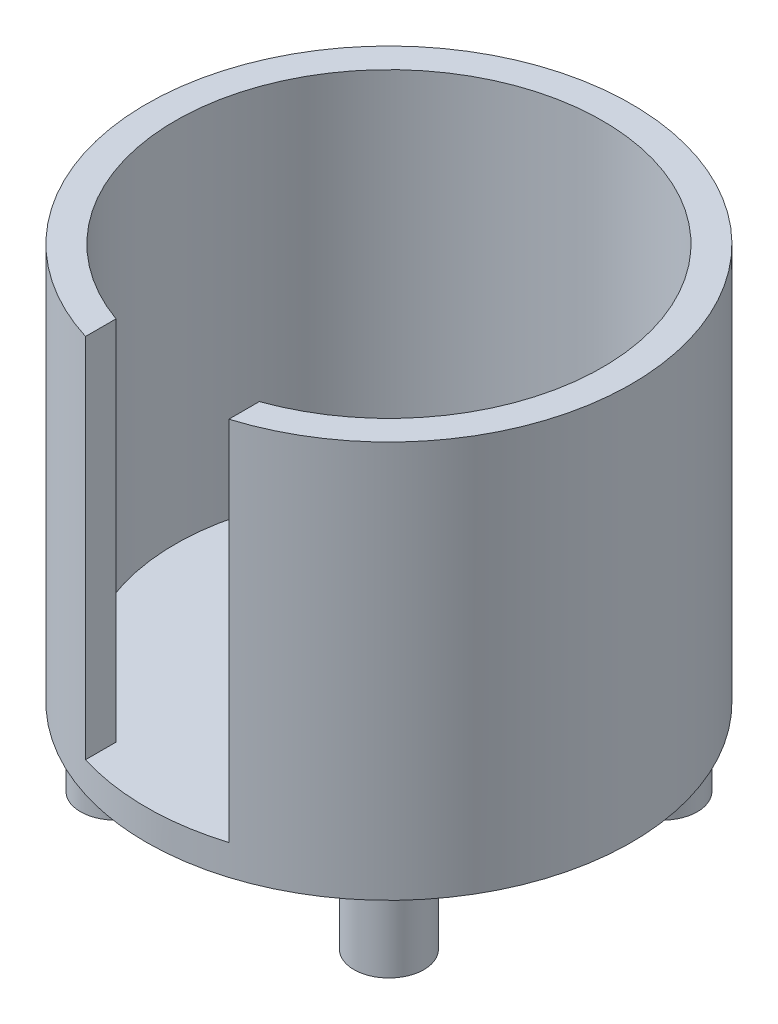
from build123d import *

# Parameters (mm, degrees)
SKETCH1_R           = 22
BOSS_EXTRUDE1_DEPTH = 36
SKETCH3_R           = 19.375
CUT_EXTRUDE1_DEPTH  = 33.25
SKETCH4_W           = 13
SKETCH4_H           = 8.241634072
CUT_EXTRUDE2_DEPTH  = 33.25
SKETCH5_R           = 3.175
BOSS_EXTRUDE2_DEPTH = 7


with BuildPart() as part:
    # Sketch1 → Boss-Extrude1 (new body)
    with BuildSketch(Plane(origin=(0, 0, 0), x_dir=(1, 0, 0), z_dir=(0, 1, 0))):
        Circle(SKETCH1_R)
    extrude(amount=BOSS_EXTRUDE1_DEPTH)

    # Sketch3 → Cut-Extrude1 (cut)
    with BuildSketch(Plane(origin=(0, 36, 0), x_dir=(1, 0, 0), z_dir=(0, 1, 0))):
        Circle(SKETCH3_R)
    extrude(amount=-CUT_EXTRUDE1_DEPTH, mode=Mode.SUBTRACT)

    # Sketch4 → Cut-Extrude2 (cut)
    with BuildSketch(Plane(origin=(0, 36, 0), x_dir=(1, 0, 0), z_dir=(0, 1, 0))):
        with Locations((0, -20.83301946)):
            Rectangle(SKETCH4_W, SKETCH4_H)
    extrude(amount=-CUT_EXTRUDE2_DEPTH, mode=Mode.SUBTRACT)

    # Sketch5 → Boss-Extrude2 (add)
    with BuildSketch(Plane(origin=(0, 0, 0), x_dir=(-1, 0, 0), z_dir=(0, -1, 0))):
        with Locations((12.386484202, -12.411737756)):
            Circle(SKETCH5_R)
        with Locations((-12.413515798, -12.411737756)):
            Circle(SKETCH5_R)
        with Locations((-12.413515798, 12.388262244)):
            Circle(SKETCH5_R)
        with Locations((12.386484202, 12.388262244)):
            Circle(SKETCH5_R)
    extrude(amount=BOSS_EXTRUDE2_DEPTH)


solid = part.part
